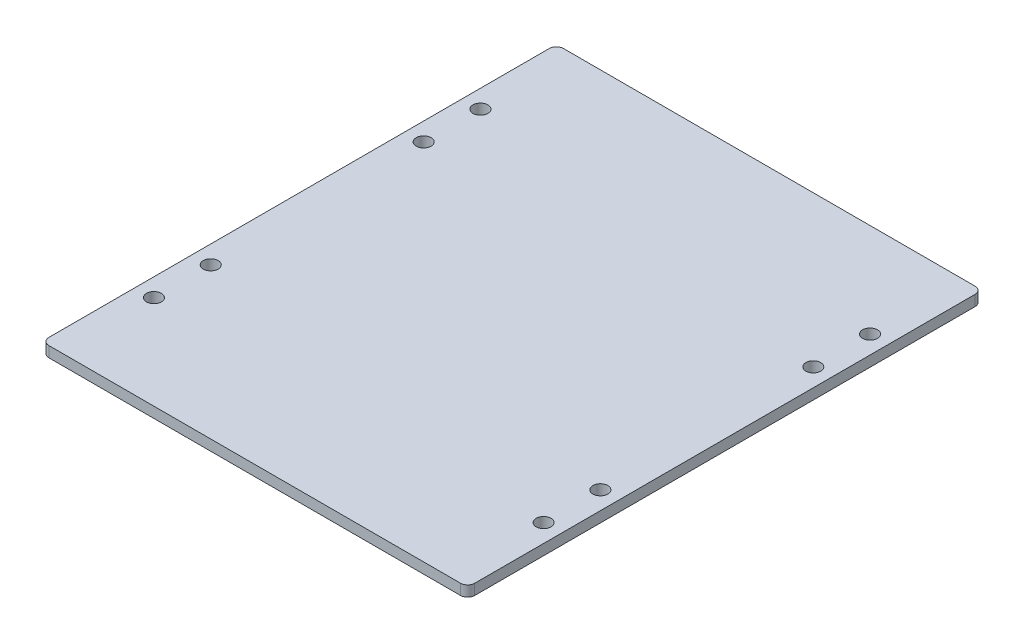
from build123d import *

# Parameters (mm, degrees)
SKETCH1_W           = 120
SKETCH1_H           = 145
BOSS_EXTRUDE1_DEPTH = 3
SKETCH2_R           = 2.1
CUT_EXTRUDE1_DEPTH  = 4
FILLET1_R           = 2


with BuildPart() as part:
    # Sketch1 → Boss-Extrude1 (new body)
    with BuildSketch(Plane(origin=(0, 0, 0), x_dir=(1, 0, 0), z_dir=(0, 1, 0))):
        with Locations((60, 72.5)):
            Rectangle(SKETCH1_W, SKETCH1_H)
    extrude(amount=BOSS_EXTRUDE1_DEPTH)

    # Sketch2 → Cut-Extrude1 (cut, through all)
    with BuildSketch(Plane(origin=(0, 3, 3), x_dir=(1, 0, 0), z_dir=(0, 1, 0))):
        with Locations((5.1, 121.5)):
            Circle(SKETCH2_R)
        with Locations((5.1, 105.5)):
            Circle(SKETCH2_R)
        with Locations((5.1, 45.5)):
            Circle(SKETCH2_R)
        with Locations((5.1, 29.5)):
            Circle(SKETCH2_R)
        with Locations((114.9, 29.5)):
            Circle(SKETCH2_R)
        with Locations((114.9, 45.5)):
            Circle(SKETCH2_R)
        with Locations((114.9, 105.5)):
            Circle(SKETCH2_R)
        with Locations((114.9, 121.5)):
            Circle(SKETCH2_R)
    extrude(amount=-CUT_EXTRUDE1_DEPTH, mode=Mode.SUBTRACT)

    # Fillet1
    fillet1_edges = [part.edges().sort_by_distance(p)[0] for p in [
        (0, 1.5, -145),
        (120, 1.5, -145),
        (120, 1.5, 0),
        (0, 1.5, 0),
    ]]
    fillet(fillet1_edges, radius=FILLET1_R)


solid = part.part
